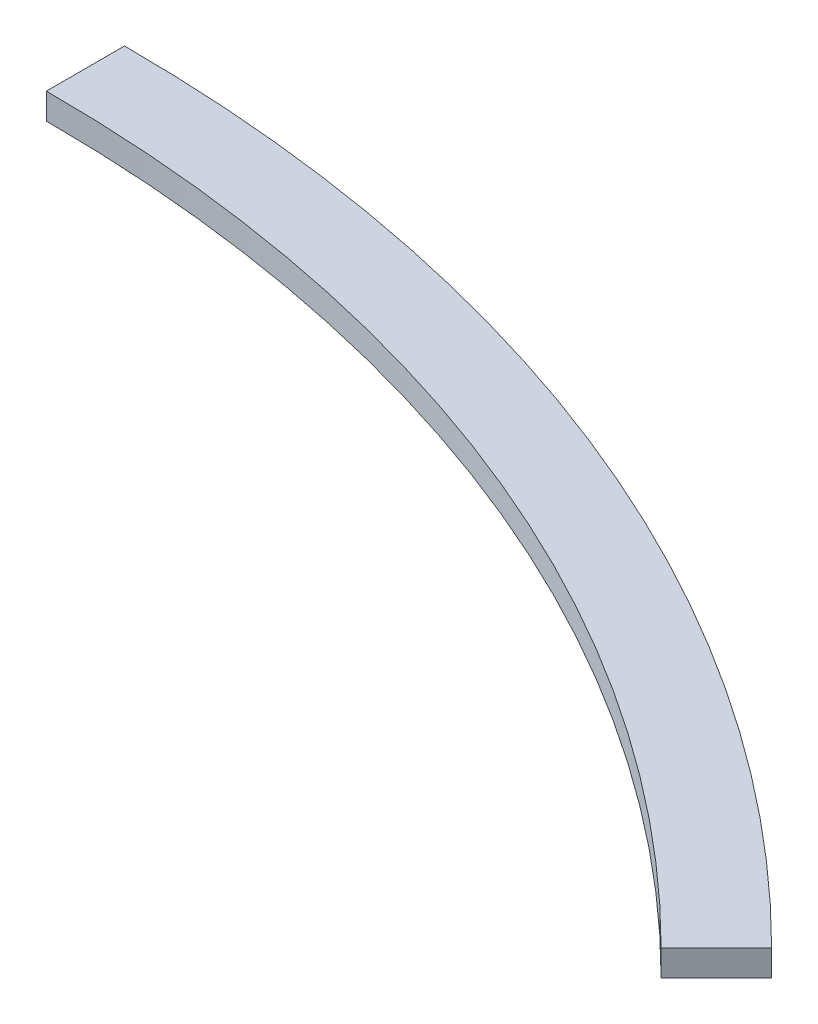
from build123d import *

# Parameters (mm, degrees)
BOSS_EXTRUDE1_DEPTH = 10


with BuildPart() as part:
    # Sketch1 → Boss-Extrude1 (new body)
    with BuildSketch(Plane(origin=(0, 0, 0), x_dir=(1, 0, 0), z_dir=(0, 1, 0))):
        with BuildLine():
            Line((0, 570), (0, 600))
            ThreePointArc((0, 600), (229.610059419, 554.327719507), (424.264068712, 424.264068712))
            Line((424.264068712, 424.264068712), (403.050865276, 403.050865276))
            ThreePointArc((403.050865276, 403.050865276), (218.129556448, 526.611333531), (0, 570))
        make_face()
    extrude(amount=BOSS_EXTRUDE1_DEPTH)


solid = part.part
